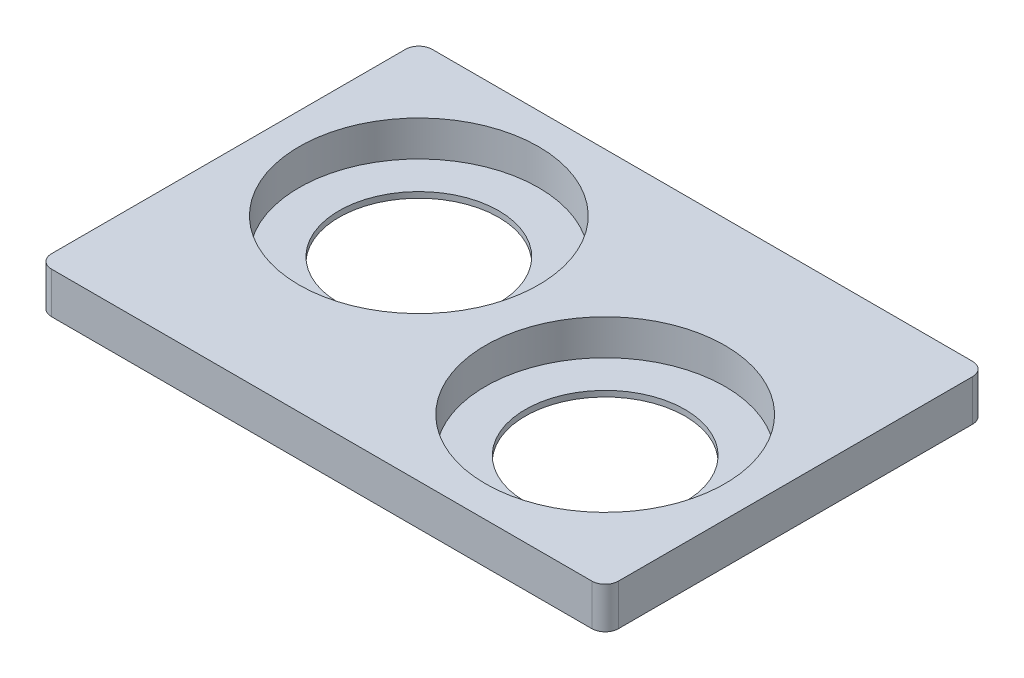
from build123d import *

# Parameters (mm, degrees)
SKETCH1_W           = 127.8
SKETCH1_H           = 85.8
BOSS_EXTRUDE1_DEPTH = 9.3
SKETCH2_R           = 27
CUT_EXTRUDE1_DEPTH  = 8
SKETCH3_R           = 18
CUT_EXTRUDE2_DEPTH  = 9
FILLET1_R           = 3
CUT_EXTRUDE3_DEPTH  = 8
FILLET2_R           = 2
FILLET3_R           = 3.5


with BuildPart() as part:
    # Sketch1 → Boss-Extrude1 (new body)
    with BuildSketch(Plane(origin=(0, 0, 0), x_dir=(1, 0, 0), z_dir=(0, 1, 0))):
        with Locations((63.9, -42.9)):
            Rectangle(SKETCH1_W, SKETCH1_H)
    extrude(amount=BOSS_EXTRUDE1_DEPTH)

    # Sketch2 → Cut-Extrude1 (cut)
    with BuildSketch(Plane(origin=(0, 9.3, 0), x_dir=(1, 0, 0), z_dir=(0, 1, 0))):
        with Locations((93.8, -51.8)):
            Circle(SKETCH2_R)
        with Locations((34, -34)):
            Circle(SKETCH2_R)
    extrude(amount=-CUT_EXTRUDE1_DEPTH, mode=Mode.SUBTRACT)

    # Sketch3 → Cut-Extrude2 (cut)
    with BuildSketch(Plane(origin=(0, 1.3, 0), x_dir=(1, 0, 0), z_dir=(0, 1, 0))):
        with Locations((93.8, -51.8)):
            Circle(SKETCH3_R)
        with Locations((34, -34)):
            Circle(SKETCH3_R)
    extrude(amount=-CUT_EXTRUDE2_DEPTH, mode=Mode.SUBTRACT)

    # Fillet1
    fillet1_edges = [part.edges().sort_by_distance(p)[0] for p in [
        (0, 4.65, 0),
        (127.8, 4.65, 0),
        (127.8, 4.65, 85.8),
        (0, 4.65, 85.8),
    ]]
    fillet(fillet1_edges, radius=FILLET1_R)

    # Sketch4 → Cut-Extrude3 (cut)
    with BuildSketch(Plane.XZ):
        with BuildLine():
            Line((52, 2), (124.8, 2))
            Line((124.8, 2), (125.8, 2))
            Line((125.8, 2), (125.8, 3))
            Line((125.8, 3), (125.8, 33.8))
            Line((125.8, 33.8), (116.8, 33.8))
            ThreePointArc((116.8, 33.8), (73.148123572, 31.148123572), (75.8, 74.8))
            Line((75.8, 74.8), (75.8, 83.8))
            Line((75.8, 83.8), (3, 83.8))
            Line((3, 83.8), (2, 83.8))
            Line((2, 83.8), (2, 82.8))
            Line((2, 82.8), (2, 52))
            Line((2, 52), (11, 52))
            ThreePointArc((11, 52), (54.651876428, 54.651876428), (52, 11))
            Line((52, 11), (52, 2))
        make_face()
        Polygon((125.3, 83.3), (125.3, 65.3), (121.8, 65.3), (107.3, 79.8), (107.3, 83.3), align=None)
        Polygon((2.5, 20.5), (2.5, 2.5), (20.5, 2.5), (20.5, 6), (6, 20.5), align=None)
    extrude(amount=-CUT_EXTRUDE3_DEPTH, mode=Mode.SUBTRACT)

    # Fillet2
    fillet2_edges = [part.edges().sort_by_distance(p)[0] for p in [
        (2.5, 4, 20.5),
        (6, 4, 20.5),
        (20.5, 4, 6),
        (20.5, 4, 2.5),
        (2.5, 4, 2.5),
        (121.8, 4, 65.3),
        (107.3, 4, 79.8),
        (107.3, 4, 83.3),
        (125.3, 4, 83.3),
        (125.3, 4, 65.3),
    ]]
    fillet(fillet2_edges, radius=FILLET2_R)

    # Fillet3
    fillet3_edges = [part.edges().sort_by_distance(p)[0] for p in [
        (125.8, 4, 2),
        (52, 4, 2),
        (52, 4, 11),
        (11, 4, 52),
        (2, 4, 52),
        (2, 4, 83.8),
        (75.8, 4, 83.8),
        (75.8, 4, 74.8),
        (116.8, 4, 33.8),
        (125.8, 4, 33.8),
    ]]
    fillet(fillet3_edges, radius=FILLET3_R)


solid = part.part
